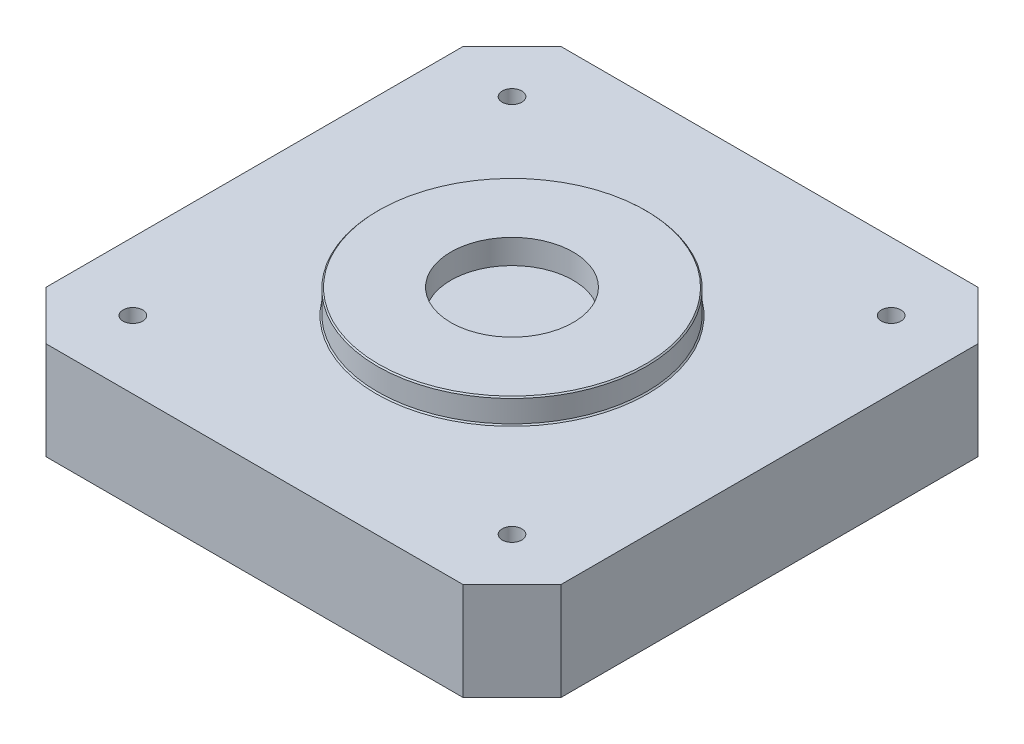
from build123d import *

# Parameters (mm, degrees)
SKETCH1_W                 = 42.1
SKETCH1_H                 = 42.1
BOSS_EXTRUDE1_DEPTH       = 8
CHAMFER1_SIZE             = 4
SKETCH2_R                 = 11
SKETCH2_R_2               = 5
BOSS_EXTRUDE2_DEPTH       = 2
CHAMFER2_SIZE             = 0.1
M2X0_4_TAPPED_HOLE1_D     = 1.6
M2X0_4_TAPPED_HOLE1_DEPTH = 8
M2X0_4_TAPPED_HOLE1_TIP   = 0.480688495


with BuildPart() as part:
    # Sketch1 → Boss-Extrude1 (new body)
    with BuildSketch(Plane(origin=(0, 0, 0), x_dir=(1, 0, 0), z_dir=(0, 1, 0))):
        Rectangle(SKETCH1_W, SKETCH1_H)
    extrude(amount=BOSS_EXTRUDE1_DEPTH)

    # Chamfer1
    chamfer1_edges = [part.edges().sort_by_distance(p)[0] for p in [
        (21.05, 4, 21.05),
        (-21.05, 4, 21.05),
        (-21.05, 4, -21.05),
        (21.05, 4, -21.05),
    ]]
    chamfer(chamfer1_edges, length=CHAMFER1_SIZE)

    # Sketch2 → Boss-Extrude2 (add)
    with BuildSketch(Plane(origin=(0, 8, 0), x_dir=(1, 0, 0), z_dir=(0, 1, 0))):
        Circle(SKETCH2_R)
        Circle(SKETCH2_R_2, mode=Mode.SUBTRACT)
    extrude(amount=BOSS_EXTRUDE2_DEPTH)

    # Chamfer2
    chamfer2_edges = [part.edges().sort_by_distance(p)[0] for p in [
        (-11, 8, 0),
        (-11, 10, 0),
    ]]
    chamfer(chamfer2_edges, length=CHAMFER2_SIZE)

    # M2x0.4 Tapped Hole1
    with Locations(Plane(origin=(-15.5, 8, -15.5), x_dir=(0, 0, 1), z_dir=(0, 1, 0))):
        with Locations((0, 0), (0, 31), (31, 31), (31, 0)):
            Hole(M2X0_4_TAPPED_HOLE1_D / 2, depth=M2X0_4_TAPPED_HOLE1_DEPTH)
            with Locations((0, 0, -(M2X0_4_TAPPED_HOLE1_DEPTH + M2X0_4_TAPPED_HOLE1_TIP / 2))):  # 118° drill point
                Cone(0, M2X0_4_TAPPED_HOLE1_D / 2, M2X0_4_TAPPED_HOLE1_TIP, mode=Mode.SUBTRACT)


solid = part.part
